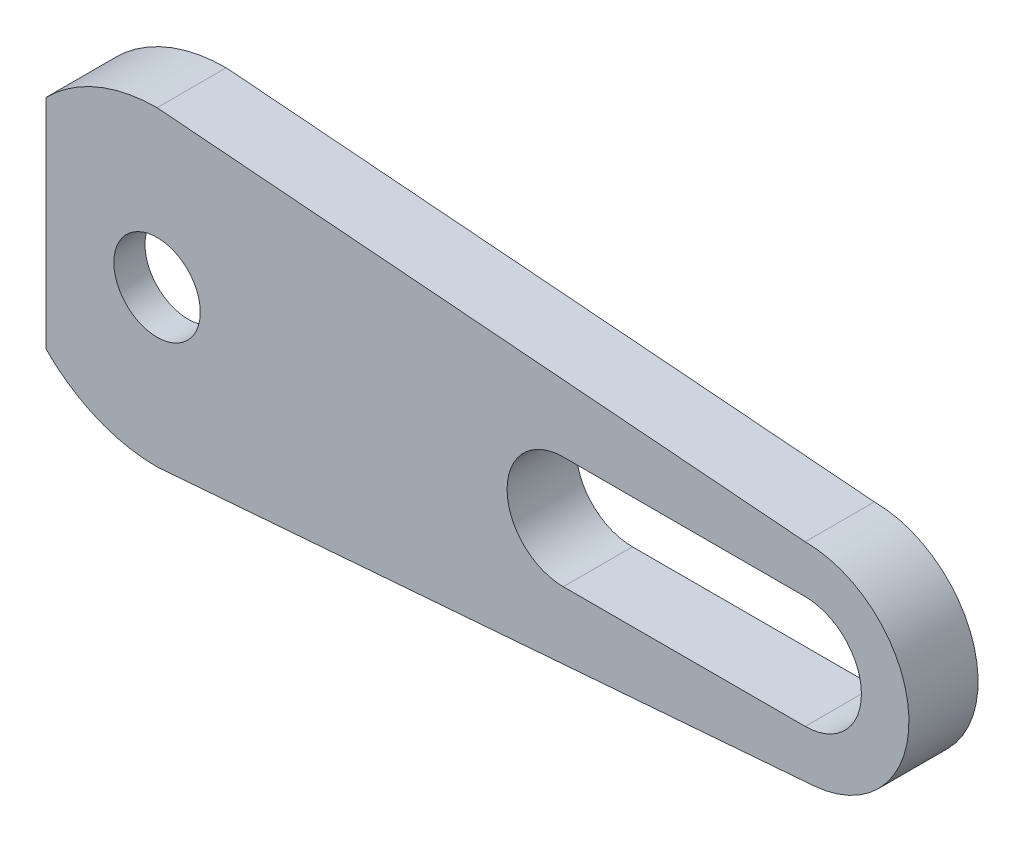
from build123d import *

# Parameters (mm, degrees)
MAIN_DEPTH          = 4
ESQUISSE2_R         = 2.5
BOSS_EXTRUDE1_DEPTH = 1.8


with BuildPart() as part:
    # Esquisse1 → Main (new body)
    with BuildSketch(Plane.XY):
        with BuildLine():
            Line((-4.375785644, 4.25), (-6.426543071, 6.300757427))
            ThreePointArc((-6.426543071, 6.300757427), (-3.48519606, 8.297795395), (0, 9))
            Line((0, 9), (37.5, 6))
            ThreePointArc((37.5, 6), (43.495280871, 0.23792284), (37.975471418, -5.981130907))
            Line((37.975471418, -5.981130907), (0, -9))
            ThreePointArc((0, -9), (-3.48519606, -8.297795395), (-6.426543071, -6.300757427))
            Line((-6.426543071, -6.300757427), (-4.375785644, -4.25))
            ThreePointArc((-4.375785644, -4.25), (0, -6.1), (4.375785644, -4.25))
            Line((4.375785644, -4.25), (17.31559729, -2.78215714))
            ThreePointArc((17.31559729, -2.78215714), (19.8, 0), (17.31559729, 2.78215714))
            Line((17.31559729, 2.78215714), (4.375785644, 4.25))
            ThreePointArc((4.375785644, 4.25), (0, 6.1), (-4.375785644, 4.25))
        make_face()
        with BuildLine():
            Line((23.5, 3.25), (37.5, 3.25))
            ThreePointArc((37.5, 3.25), (40.75, 0), (37.5, -3.25))
            Line((37.5, -3.25), (23.5, -3.25))
            ThreePointArc((23.5, -3.25), (20.25, 0), (23.5, 3.25))
        make_face(mode=Mode.SUBTRACT)
    extrude(amount=MAIN_DEPTH)

    # Esquisse2 → Boss-Extrude1 (add)
    with BuildSketch(Plane(origin=(0, 0, 4), x_dir=(-1, 0, 0), z_dir=(0, 0, -1))):
        with BuildLine():
            Line((0, -9), (-12.890260848, -7.975285662))
            ThreePointArc((-12.890260848, -7.975285662), (-20.25000047, -0.003253265), (-12.890260848, 7.968779132))
            Line((-12.890260848, 7.968779132), (0, 9))
            ThreePointArc((0, 9), (3.48519606, 8.297795395), (6.426543071, 6.300757427))
            Line((6.426543071, 6.300757427), (6.426543071, -6.300757427))
            ThreePointArc((6.426543071, -6.300757427), (3.48519606, -8.297795395), (0, -9))
        make_face()
        Circle(ESQUISSE2_R, mode=Mode.SUBTRACT)
    extrude(amount=BOSS_EXTRUDE1_DEPTH)


solid = part.part
